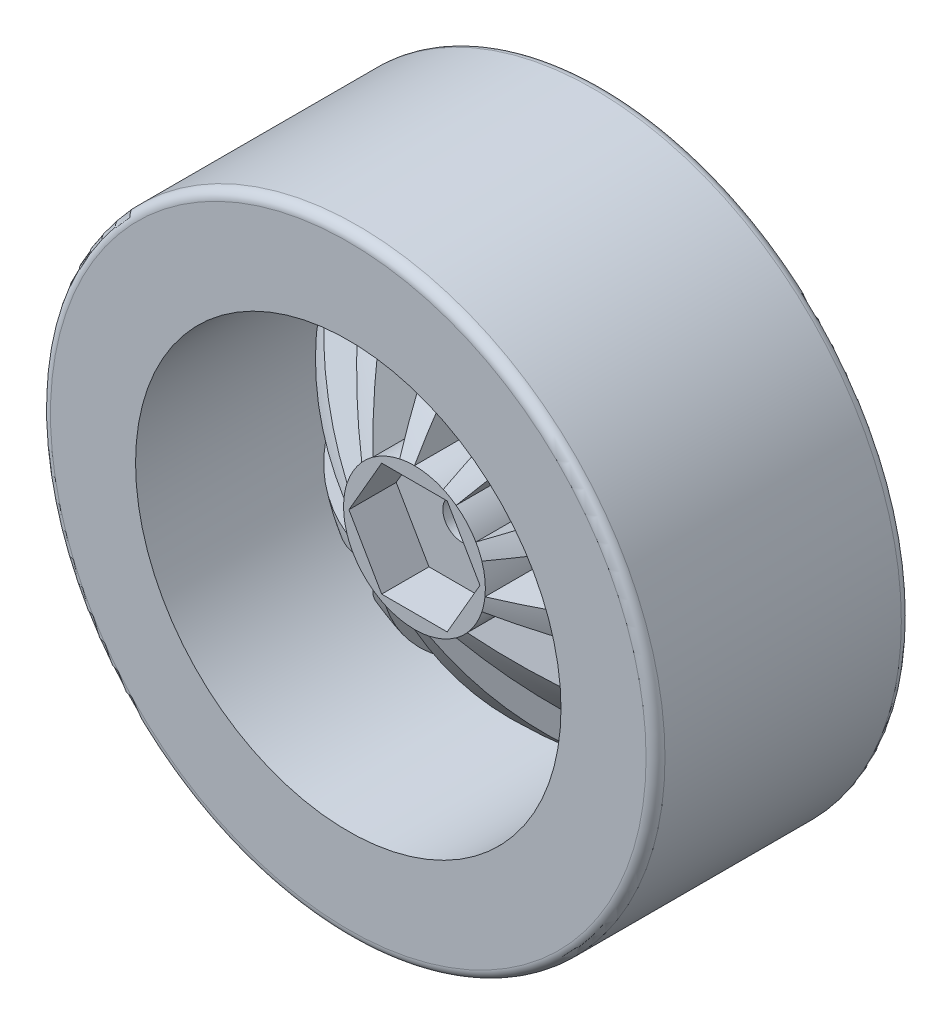
from build123d import *

# Parameters (mm, degrees)
SKETCH_1_R               = 7.5
EXTRUDE_1_DEPTH          = 5
SKETCH_2_R               = 7.5
SKETCH_2_R_2             = 2
EXTRUDE_2_DEPTH          = 3
SKETCH_3_R               = 32.5
SKETCH_3_R_2             = 22.5
EXTRUDE_3_DEPTH          = 12
EXTRUDE_3_DEPTH_BACK     = 15
REVOLVE_1_ANGLE          = 12
PATTERN_CIRCULAR_1_COUNT = 10
SKETCH_5_R               = 4.5
CUT_EXTRUDE_1_DEPTH      = 2
FILLET_1_R               = 1


with BuildPart() as part:
    # 草图1 → 凸台-拉伸1 (new body)
    with BuildSketch(Plane.XY):
        Circle(SKETCH_1_R)
        Polygon((-6.92820323, 0), (-3.464101615, -6), (3.464101615, -6), (6.92820323, 0), (3.464101615, 6), (-3.464101615, 6), align=None, mode=Mode.SUBTRACT)
    extrude(amount=EXTRUDE_1_DEPTH)

    # 草图2 → 凸台-拉伸2 (add)
    with BuildSketch(Plane.XY):
        Circle(SKETCH_2_R)
        Circle(SKETCH_2_R_2, mode=Mode.SUBTRACT)
    extrude(amount=-EXTRUDE_2_DEPTH)



with BuildPart() as body_2:
    # 草图3 → 凸台-拉伸3 (new body, two sides)
    with BuildSketch(Plane.XY) as extrude_3_sk:
        Circle(SKETCH_3_R)
        Circle(SKETCH_3_R_2, mode=Mode.SUBTRACT)
    extrude(amount=EXTRUDE_3_DEPTH)
    extrude(extrude_3_sk.sketch, amount=-EXTRUDE_3_DEPTH_BACK)


with BuildPart() as part_1:
    add(part.part)

    add(body_2.part)  # 旋转1 merges body 2
    # 草图4 → 旋转1 (revolve)
    with BuildSketch(Plane(origin=(0, 0, 0), x_dir=(0, 0, -1), z_dir=(1, 0, 0))):
        with BuildLine():
            Line((-5, 7.5), (3, 7.5))
            ThreePointArc((3, 7.5), (7.415092079, 16.267926336), (15, 22.5))
            Line((15, 22.5), (7, 22.5))
            ThreePointArc((7, 22.5), (0.420622129, 15.463502297), (-5, 7.5))
        make_face()
    revolve_1 = revolve(axis=Axis((0, 0, -16.35), (0, 0, 1)), revolution_arc=REVOLVE_1_ANGLE)

    # 阵列(圆周)1: 旋转1 ×10 about axis
    pattern_circular_1_axis = Axis((0, 0, 0), (0, 0, 1))
    for i in range(1, PATTERN_CIRCULAR_1_COUNT):
        add(revolve_1.rotate(pattern_circular_1_axis, i * 360 / PATTERN_CIRCULAR_1_COUNT))

    # 草图5 → 切除-拉伸1 (cut)
    with BuildSketch(Plane(origin=(0, 0, -3), x_dir=(-1, 0, 0), z_dir=(0, 0, -1))):
        Circle(SKETCH_5_R)
    extrude(amount=-CUT_EXTRUDE_1_DEPTH, mode=Mode.SUBTRACT)

    # 圆角1
    fillet_1_edges = [part_1.edges().sort_by_distance(p)[0] for p in [
        (-32.5, 0, -15),
        (-32.5, 0, 12),
    ]]
    fillet(fillet_1_edges, radius=FILLET_1_R)


solid = part_1.part
